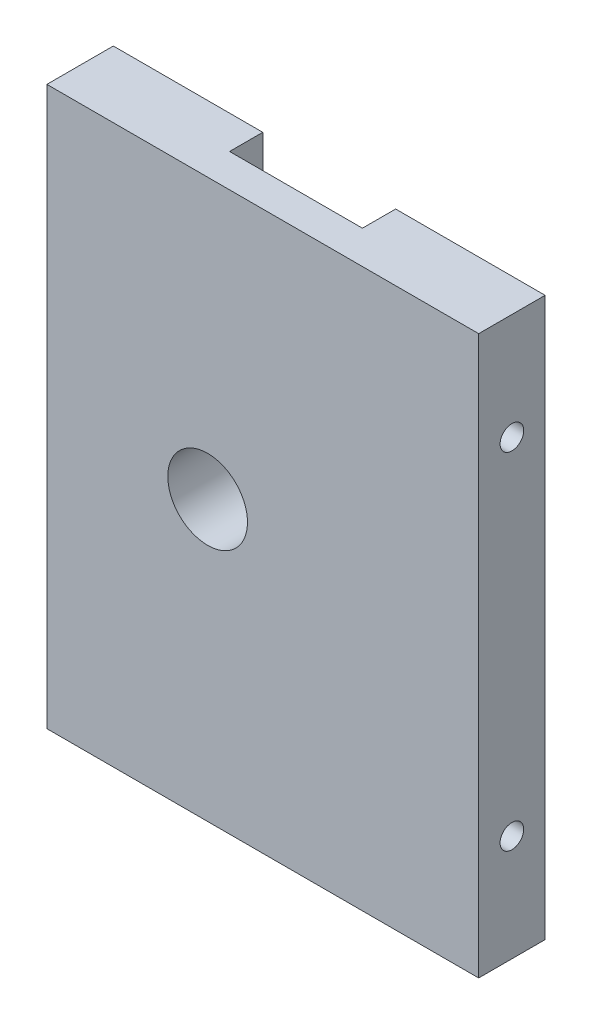
from build123d import *

# Parameters (mm, degrees)
SKETCH1_W                 = 32.5
SKETCH1_H                 = 42
BOSS_EXTRUDE2_DEPTH       = 5
F_2_56_TAPPED_HOLE1_D     = 1.778
F_2_56_TAPPED_HOLE1_DEPTH = 7.46583491
F_2_56_TAPPED_HOLE1_TIP   = 0.53416509
F_2_56_TAPPED_HOLE2_D     = 1.778
F_2_56_TAPPED_HOLE2_DEPTH = 7.46583491
F_2_56_TAPPED_HOLE2_TIP   = 0.53416509
CUT_EXTRUDE1_DEPTH        = 5
SKETCH10_W                = 10
SKETCH10_H                = 6.5
CUT_EXTRUDE2_DEPTH        = 2.5


with BuildPart() as part:
    # Sketch1 → Boss-Extrude2 (new body)
    with BuildSketch(Plane.XY):
        with Locations((16.25, 21)):
            Rectangle(SKETCH1_W, SKETCH1_H)
    extrude(amount=BOSS_EXTRUDE2_DEPTH)

    # #2-56 Tapped Hole1
    with Locations(Plane.ZY):
        with Locations((2.5, 34), (2.5, 8)):
            Hole(F_2_56_TAPPED_HOLE1_D / 2, depth=F_2_56_TAPPED_HOLE1_DEPTH)
            with Locations((0, 0, -(F_2_56_TAPPED_HOLE1_DEPTH + F_2_56_TAPPED_HOLE1_TIP / 2))):  # 118° drill point
                Cone(0, F_2_56_TAPPED_HOLE1_D / 2, F_2_56_TAPPED_HOLE1_TIP, mode=Mode.SUBTRACT)

    # #2-56 Tapped Hole2
    with Locations(Plane(origin=(32.5, 0, 0), x_dir=(0, 0, -1), z_dir=(1, 0, 0))):
        with Locations((-2.5, 34), (-2.5, 8)):
            Hole(F_2_56_TAPPED_HOLE2_D / 2, depth=F_2_56_TAPPED_HOLE2_DEPTH)
            with Locations((0, 0, -(F_2_56_TAPPED_HOLE2_DEPTH + F_2_56_TAPPED_HOLE2_TIP / 2))):  # 118° drill point
                Cone(0, F_2_56_TAPPED_HOLE2_D / 2, F_2_56_TAPPED_HOLE2_TIP, mode=Mode.SUBTRACT)

    # Sketch9 → Cut-Extrude1 (cut)
    with BuildSketch(Plane(origin=(0, 0, 0), x_dir=(-1, 0, 0), z_dir=(0, 0, -1))):
        with BuildLine():
            ThreePointArc((-15.1, 21), (-12.1, 18), (-9.1, 21))
            Line((-9.1, 21), (-12.1, 21))
            Line((-12.1, 21), (-15.1, 21))
        make_face()
        with BuildLine():
            Line((-12.1, 21), (-9.1, 21))
            ThreePointArc((-9.1, 21), (-12.1, 24), (-15.1, 21))
            Line((-15.1, 21), (-12.1, 21))
        make_face()
    extrude(amount=-CUT_EXTRUDE1_DEPTH, mode=Mode.SUBTRACT)

    # Sketch10 → Cut-Extrude2 (cut)
    with BuildSketch(Plane(origin=(0, 0, 0), x_dir=(-1, 0, 0), z_dir=(0, 0, -1))):
        with Locations((-16.25, 38.75)):
            Rectangle(SKETCH10_W, SKETCH10_H)
    extrude(amount=-CUT_EXTRUDE2_DEPTH, mode=Mode.SUBTRACT)


solid = part.part
